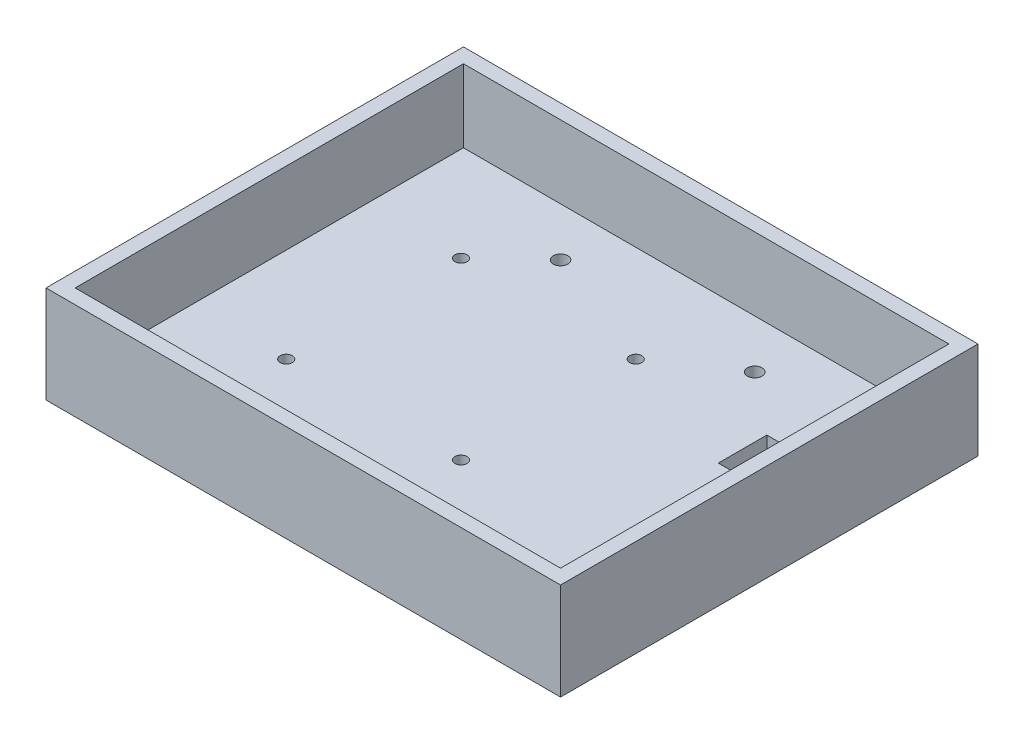
from build123d import *

# Parameters (mm, degrees)
SKETCH_1_W               = 100
SKETCH_1_H               = 80
EXTRUDE_1_DEPTH          = 5
SKETCH_2_R               = 1.5
CUT_EXTRUDE_1_DEPTH      = 6
MIRROR_2_COPY_1_SKETCH_R = 1.5
MIRROR_2_COPY_1_DEPTH    = 6
SKETCH_4_W               = 100
SKETCH_4_H               = 20
EXTRUDE_2_DEPTH          = 3
SKETCH_5_W               = 83
SKETCH_5_H               = 20
EXTRUDE_3_DEPTH          = 3
SKETCH_6_W               = 106
SKETCH_6_H               = 20
EXTRUDE_4_DEPTH          = 3
SKETCH_7_R               = 1.25
CUT_EXTRUDE_2_DEPTH      = 6
CUT_EXTRUDE_3_DEPTH      = 2
SKETCH_9_W               = 15
SKETCH_9_H               = 10
CUT_EXTRUDE_4_DEPTH      = 6


with BuildPart() as part:
    # 草图1 → 凸台-拉伸1 (new body)
    with BuildSketch(Plane(origin=(0, 0, 0), x_dir=(1, 0, 0), z_dir=(0, 1, 0))):
        Rectangle(SKETCH_1_W, SKETCH_1_H)
    extrude(amount=EXTRUDE_1_DEPTH)

    # 草图2 → 切除-拉伸1 (cut, through all)
    with BuildSketch(Plane(origin=(0, 5, 0), x_dir=(1, 0, 0), z_dir=(0, 1, 0))):
        with Locations((20, 30)):
            Circle(SKETCH_2_R)
    cut_extrude_1 = extrude(amount=-CUT_EXTRUDE_1_DEPTH, mode=Mode.SUBTRACT)

    # 镜向1: 切除-拉伸1 across plane
    add(cut_extrude_1.mirror(Plane.ZY), mode=Mode.SUBTRACT)

    # 镜向2: 切除-拉伸1 across plane
    add(cut_extrude_1.mirror(Plane.XY), mode=Mode.SUBTRACT)

    # 镜向2 copy 1 sketch → 镜向2 copy 1 (cut, through all)
    with BuildSketch(Plane(origin=(0, 5, 0), x_dir=(-1, 0, 0), z_dir=(0, 1, 0))):
        with Locations((20, 30)):
            Circle(MIRROR_2_COPY_1_SKETCH_R)
    extrude(amount=-MIRROR_2_COPY_1_DEPTH, mode=Mode.SUBTRACT)

    # 草图4 → 凸台-拉伸2 (add)
    with BuildSketch(Plane.XY.offset(40)):
        with Locations((0, 10)):
            Rectangle(SKETCH_4_W, SKETCH_4_H)
    extrude(amount=EXTRUDE_2_DEPTH)

    # 草图5 → 凸台-拉伸3 (add)
    with BuildSketch(Plane.ZY.offset(50)):
        with Locations((1.5, 10)):
            Rectangle(SKETCH_5_W, SKETCH_5_H)
    extrude_3 = extrude(amount=EXTRUDE_3_DEPTH)

    # 镜向3: 凸台-拉伸3 across plane
    add(extrude_3.mirror(Plane.ZY))

    # 草图6 → 凸台-拉伸4 (add)
    with BuildSketch(Plane(origin=(0, 0, -40), x_dir=(-1, 0, 0), z_dir=(0, 0, -1))):
        with Locations((0, 10)):
            Rectangle(SKETCH_6_W, SKETCH_6_H)
    extrude(amount=EXTRUDE_4_DEPTH)

    # 草图7 → 切除-拉伸2 (cut, through all)
    with BuildSketch(Plane(origin=(0, 5, 0), x_dir=(1, 0, 0), z_dir=(0, 1, 0))):
        with Locations((5.45, 20.04)):
            Circle(SKETCH_7_R)
        with Locations((-30.55, 20.04)):
            Circle(SKETCH_7_R)
        with Locations((-30.55, -15.96)):
            Circle(SKETCH_7_R)
        with Locations((5.45, -15.96)):
            Circle(SKETCH_7_R)
    extrude(amount=-CUT_EXTRUDE_2_DEPTH, mode=Mode.SUBTRACT)

    # 草图8 → 切除-拉伸3 (cut)
    with BuildSketch(Plane.XZ):
        Polygon((-28.01123046, 17.425759277), (-30.55, 18.891518554), (-33.08876954, 17.425759277), (-33.08876954, 14.494240723), (-30.55, 13.028481446), (-28.01123046, 14.494240723), align=None)
        Polygon((-30.55, -17.0377786), (-33.15, -18.5388893), (-33.15, -21.5411107), (-30.55, -23.0422214), (-27.95, -21.5411107), (-27.95, -18.5388893), align=None)
        Polygon((5.45, 18.9622214), (2.85, 17.4611107), (2.85, 14.4588893), (5.45, 12.9577786), (8.05, 14.4588893), (8.05, 17.4611107), align=None)
        Polygon((5.45, -17.0377786), (2.85, -18.5388893), (2.85, -21.5411107), (5.45, -23.0422214), (8.05, -21.5411107), (8.05, -18.5388893), align=None)
    extrude(amount=-CUT_EXTRUDE_3_DEPTH, mode=Mode.SUBTRACT)

    # 草图9 → 切除-拉伸4 (cut, through all)
    with BuildSketch(Plane(origin=(0, 5, 0), x_dir=(1, 0, 0), z_dir=(0, 1, 0))):
        with Locations((40, 15)):
            Rectangle(SKETCH_9_W, SKETCH_9_H)
    extrude(amount=-CUT_EXTRUDE_4_DEPTH, mode=Mode.SUBTRACT)


solid = part.part
